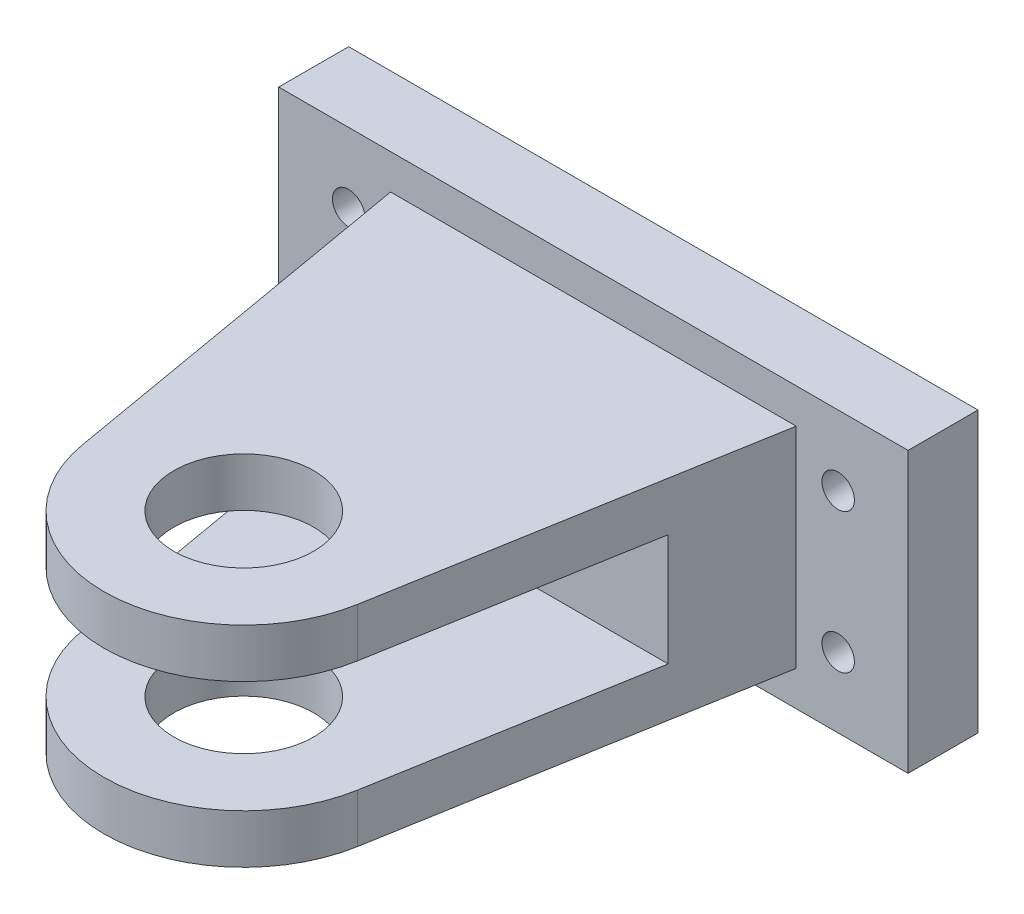
from build123d import *

# Parameters (mm, degrees)
SKETCH1_W                 = 57.15
SKETCH1_H                 = 25.4
BOSS_EXTRUDE1_DEPTH       = 6.35
F_4_CLEARANCE_HOLE1_D     = 2.9464
F_4_CLEARANCE_HOLE1_DEPTH = 6.35
SKETCH4_R                 = 6.35
BOSS_EXTRUDE2_DEPTH       = 9.525
SKETCH5_R                 = 6.35
BOSS_EXTRUDE3_DEPTH       = 9.525
CUT_EXTRUDE1_DEPTH        = 5.08


with BuildPart() as part:
    # Sketch1 → Boss-Extrude1 (new body)
    with BuildSketch(Plane.XY):
        Rectangle(SKETCH1_W, SKETCH1_H)
    extrude(amount=BOSS_EXTRUDE1_DEPTH)

    # 4 Clearance Hole1
    with Locations(Plane.XY.offset(6.35)):
        with Locations((-22.225, 6.35), (22.225, -6.35), (-22.225, -6.35), (22.225, 6.35)):
            Hole(F_4_CLEARANCE_HOLE1_D / 2, depth=F_4_CLEARANCE_HOLE1_DEPTH)

    # Sketch4 → Boss-Extrude2 (add, symmetric)
    with BuildSketch(Plane(origin=(0, 0, 0), x_dir=(1, 0, 0), z_dir=(0, 1, 0))):
        with BuildLine():
            Line((-12.512025451, -40.276974762), (-18.415, -6.35))
            Line((-18.415, -6.35), (18.415, -6.35))
            Line((18.415, -6.35), (12.512025451, -40.276974762))
            ThreePointArc((12.512025451, -40.276974762), (0, -50.8), (-12.512025451, -40.276974762))
        make_face()
        with Locations((0, -38.1)):
            Circle(SKETCH4_R, mode=Mode.SUBTRACT)
    extrude(amount=BOSS_EXTRUDE2_DEPTH, both=True)

    # Sketch5 → Boss-Extrude3 (add, symmetric)
    with BuildSketch(Plane(origin=(0, 0, 0), x_dir=(1, 0, 0), z_dir=(0, 1, 0))):
        with BuildLine():
            Line((17.641611802, -10.795), (-17.641611802, -10.795))
            Line((-17.641611802, -10.795), (-12.512025451, -40.276974762))
            ThreePointArc((-12.512025451, -40.276974762), (0, -50.8), (12.512025451, -40.276974762))
            Line((12.512025451, -40.276974762), (17.641611802, -10.795))
        make_face()
        with Locations((0, -38.1)):
            Circle(SKETCH5_R, mode=Mode.SUBTRACT)
    extrude(amount=BOSS_EXTRUDE3_DEPTH, both=True)

    # Sketch6 → Cut-Extrude1 (cut, symmetric)
    with BuildSketch(Plane(origin=(0, 0, 0), x_dir=(1, 0, 0), z_dir=(0, 1, 0))):
        with BuildLine():
            Line((-16.691449159, -16.256), (16.691449159, -16.256))
            Line((16.691449159, -16.256), (12.512025451, -40.276974762))
            ThreePointArc((12.512025451, -40.276974762), (0, -50.8), (-12.512025451, -40.276974762))
            Line((-12.512025451, -40.276974762), (-16.691449159, -16.256))
        make_face()
    extrude(amount=CUT_EXTRUDE1_DEPTH, both=True, mode=Mode.SUBTRACT)


solid = part.part
